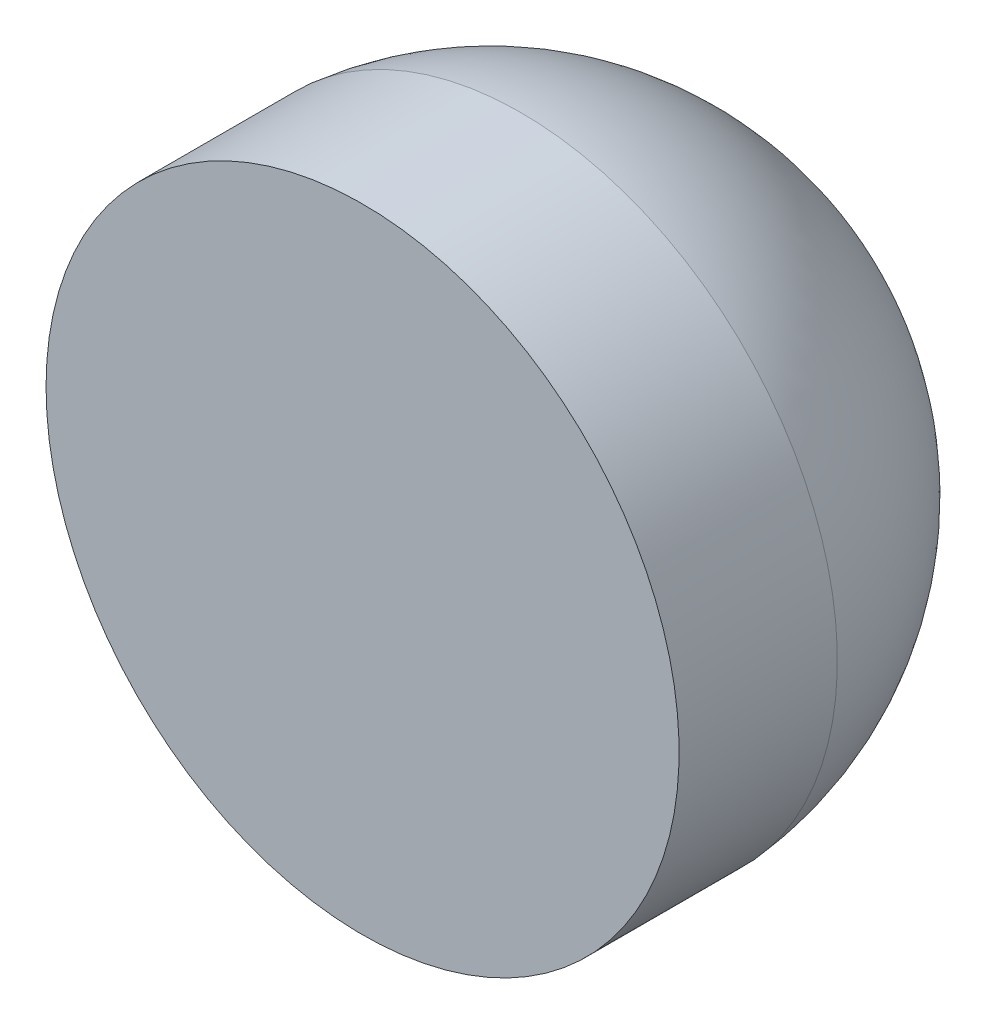
from build123d import *


with BuildPart() as part:
    # Sketch4 → Revolve1 (revolve)
    with BuildSketch(Plane(origin=(0, 0, 0), x_dir=(1, 0, 0), z_dir=(0, 1, 0))):
        with BuildLine():
            Line((0, 5.9), (2.5, 5.9))
            Line((2.5, 5.9), (2.5, 7.9))
            ThreePointArc((2.5, 7.9), (4.909210346, 5.920864533), (6, 3))
            Line((6, 3), (6, 0))
            Line((6, 0), (0, 0))
            Line((0, 0), (0, 5.9))
        make_face()
    revolve(axis=Axis((0, 0, -5.9), (0, 0, 1)))


solid = part.part
